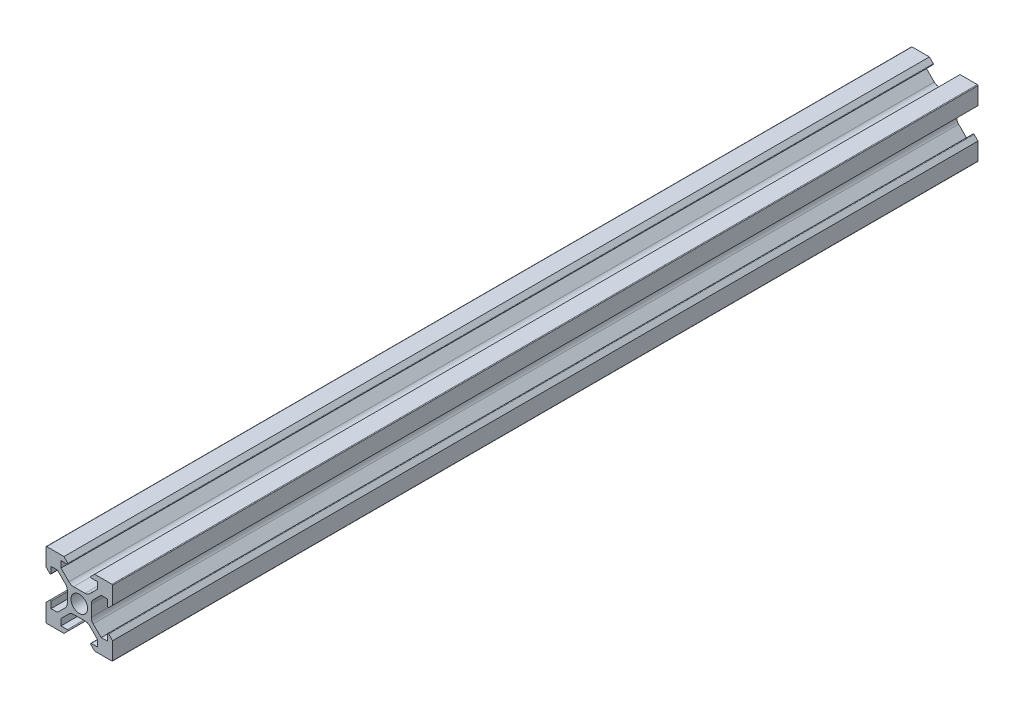
from build123d import *

# Parameters (mm, degrees)
ESBO_O1_R                = 2.5
RESSALTO_EXTRUS_O1_DEPTH = 260


with BuildPart() as part:
    # Esboço1 → Ressalto-extrusão1 (new body)
    with BuildSketch(Plane.XY):
        with BuildLine():
            Line((-4.6, -10), (-9.8, -10))
            ThreePointArc((-9.8, -10), (-9.941421356, -9.941421356), (-10, -9.8))
            Line((-10, -9.8), (-10, -4.6))
            Line((-10, -4.6), (-8.841421356, -3.441421356))
            ThreePointArc((-8.841421356, -3.441421356), (-8.623463314, -3.398066806), (-8.5, -3.582842712))
            Line((-8.5, -3.582842712), (-8.5, -5.5))
            Line((-8.5, -5.5), (-6.560660172, -5.5))
            Line((-6.560660172, -5.5), (-4.185786438, -3.125126266))
            ThreePointArc((-4.185786438, -3.125126266), (-3.752240935, -2.476279568), (-3.6, -1.710912703))
            Line((-3.6, -1.710912703), (-3.6, 1.710912703))
            ThreePointArc((-3.6, 1.710912703), (-3.752240935, 2.476279568), (-4.185786438, 3.125126266))
            Line((-4.185786438, 3.125126266), (-6.560660172, 5.5))
            Line((-6.560660172, 5.5), (-8.5, 5.5))
            Line((-8.5, 5.5), (-8.5, 3.582842712))
            ThreePointArc((-8.5, 3.582842712), (-8.623463314, 3.398066806), (-8.841421356, 3.441421356))
            Line((-8.841421356, 3.441421356), (-10, 4.6))
            Line((-10, 4.6), (-10, 9.8))
            ThreePointArc((-10, 9.8), (-9.941421356, 9.941421356), (-9.8, 10))
            Line((-9.8, 10), (-4.6, 10))
            Line((-4.6, 10), (-3.441421356, 8.841421356))
            ThreePointArc((-3.441421356, 8.841421356), (-3.398066806, 8.623463314), (-3.582842712, 8.5))
            Line((-3.582842712, 8.5), (-5.5, 8.5))
            Line((-5.5, 8.5), (-5.5, 6.560660172))
            Line((-5.5, 6.560660172), (-3.125126266, 4.185786438))
            ThreePointArc((-3.125126266, 4.185786438), (-2.476279568, 3.752240935), (-1.710912703, 3.6))
            Line((-1.710912703, 3.6), (1.710912703, 3.6))
            ThreePointArc((1.710912703, 3.6), (2.476279568, 3.752240935), (3.125126266, 4.185786438))
            Line((3.125126266, 4.185786438), (5.5, 6.560660172))
            Line((5.5, 6.560660172), (5.5, 8.5))
            Line((5.5, 8.5), (3.582842712, 8.5))
            ThreePointArc((3.582842712, 8.5), (3.398066806, 8.623463314), (3.441421356, 8.841421356))
            Line((3.441421356, 8.841421356), (4.6, 10))
            Line((4.6, 10), (9.8, 10))
            ThreePointArc((9.8, 10), (9.941421356, 9.941421356), (10, 9.8))
            Line((10, 9.8), (10, 4.6))
            Line((10, 4.6), (8.841421356, 3.441421356))
            ThreePointArc((8.841421356, 3.441421356), (8.623463314, 3.398066806), (8.5, 3.582842712))
            Line((8.5, 3.582842712), (8.5, 5.5))
            Line((8.5, 5.5), (6.560660172, 5.5))
            Line((6.560660172, 5.5), (4.185786438, 3.125126266))
            ThreePointArc((4.185786438, 3.125126266), (3.752240935, 2.476279568), (3.6, 1.710912703))
            Line((3.6, 1.710912703), (3.6, -1.710912703))
            ThreePointArc((3.6, -1.710912703), (3.752240935, -2.476279568), (4.185786438, -3.125126266))
            Line((4.185786438, -3.125126266), (6.560660172, -5.5))
            Line((6.560660172, -5.5), (8.5, -5.5))
            Line((8.5, -5.5), (8.5, -3.582842712))
            ThreePointArc((8.5, -3.582842712), (8.623463314, -3.398066806), (8.841421356, -3.441421356))
            Line((8.841421356, -3.441421356), (10, -4.6))
            Line((10, -4.6), (10, -9.8))
            ThreePointArc((10, -9.8), (9.941421356, -9.941421356), (9.8, -10))
            Line((9.8, -10), (4.6, -10))
            Line((4.6, -10), (3.441421356, -8.841421356))
            ThreePointArc((3.441421356, -8.841421356), (3.398066806, -8.623463314), (3.582842712, -8.5))
            Line((3.582842712, -8.5), (5.5, -8.5))
            Line((5.5, -8.5), (5.5, -6.560660172))
            Line((5.5, -6.560660172), (3.125126266, -4.185786438))
            ThreePointArc((3.125126266, -4.185786438), (2.476279568, -3.752240935), (1.710912703, -3.6))
            Line((1.710912703, -3.6), (-1.710912703, -3.6))
            ThreePointArc((-1.710912703, -3.6), (-2.476279568, -3.752240935), (-3.125126266, -4.185786438))
            Line((-3.125126266, -4.185786438), (-5.5, -6.560660172))
            Line((-5.5, -6.560660172), (-5.5, -8.5))
            Line((-5.5, -8.5), (-3.582842712, -8.5))
            ThreePointArc((-3.582842712, -8.5), (-3.398066806, -8.623463314), (-3.441421356, -8.841421356))
            Line((-3.441421356, -8.841421356), (-4.6, -10))
        make_face()
        Circle(ESBO_O1_R, mode=Mode.SUBTRACT)
    extrude(amount=RESSALTO_EXTRUS_O1_DEPTH)


solid = part.part
